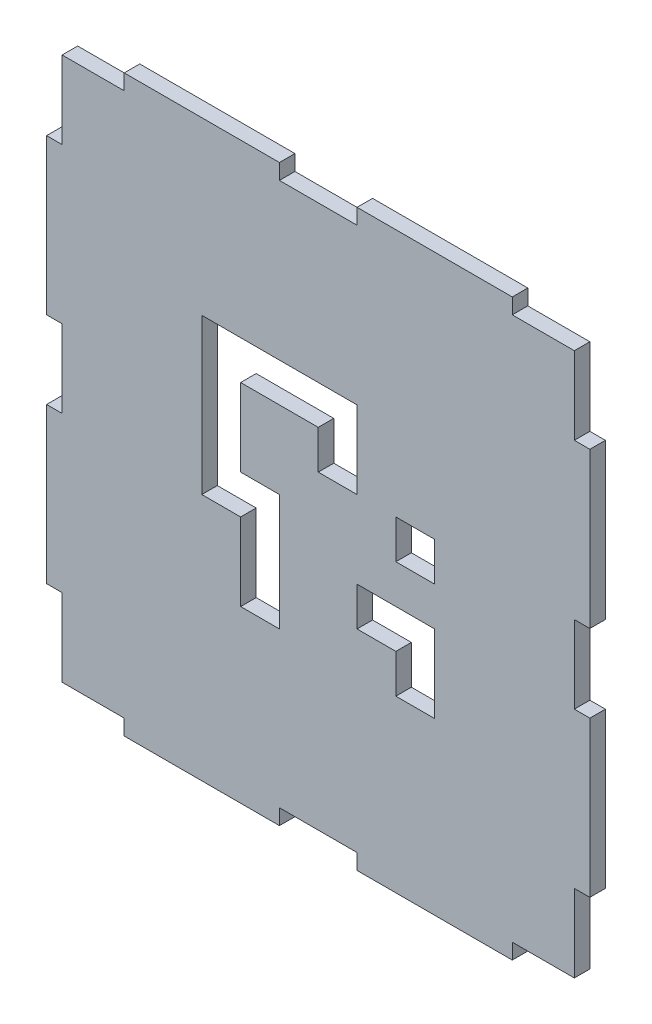
from build123d import *

# Parameters (mm, degrees)
SKETCH1_W           = 66
SKETCH1_H           = 70
BOSS_EXTRUDE1_DEPTH = 2
SKETCH2_W           = 2
SKETCH2_H           = 20
BOSS_EXTRUDE2_DEPTH = 2
SKETCH3_W           = 20
SKETCH3_H           = 2
BOSS_EXTRUDE3_DEPTH = 2
SKETCH8_W           = 5
SKETCH8_H           = 5
CUT_EXTRUDE4_DEPTH  = 10


with BuildPart() as part:
    # Sketch1 → Boss-Extrude1 (new body)
    with BuildSketch(Plane.XY):
        Rectangle(SKETCH1_W, SKETCH1_H)
    extrude(amount=BOSS_EXTRUDE1_DEPTH)

    # Sketch2 → Boss-Extrude2 (add)
    with BuildSketch(Plane(origin=(0, 0, 0), x_dir=(-1, 0, 0), z_dir=(0, 0, -1))):
        with Locations((34, -15)):
            Rectangle(SKETCH2_W, SKETCH2_H)
        with Locations((34, 15)):
            Rectangle(SKETCH2_W, SKETCH2_H)
        with Locations((-34, -15)):
            Rectangle(SKETCH2_W, SKETCH2_H)
        with Locations((-34, 15)):
            Rectangle(SKETCH2_W, SKETCH2_H)
    extrude(amount=-BOSS_EXTRUDE2_DEPTH)

    # Sketch3 → Boss-Extrude3 (add)
    with BuildSketch(Plane(origin=(0, 0, 0), x_dir=(-1, 0, 0), z_dir=(0, 0, -1))):
        with Locations((-15, 36)):
            Rectangle(SKETCH3_W, SKETCH3_H)
        with Locations((15, 36)):
            Rectangle(SKETCH3_W, SKETCH3_H)
        with Locations((-15, -36)):
            Rectangle(SKETCH3_W, SKETCH3_H)
        with Locations((15, -36)):
            Rectangle(SKETCH3_W, SKETCH3_H)
    extrude(amount=-BOSS_EXTRUDE3_DEPTH)

    # Sketch8 → Cut-Extrude4 (cut)
    with BuildSketch(Plane(origin=(0, 0, 0), x_dir=(-1, 0, 0), z_dir=(0, 0, -1))):
        with Locations((-12.5, -12.550886484)):
            Rectangle(SKETCH8_W, SKETCH8_H)
        with Locations((-12.5, -7.550886484)):
            Rectangle(SKETCH8_W, SKETCH8_H)
        with Locations((-7.5, -7.550886484)):
            Rectangle(SKETCH8_W, SKETCH8_H)
        with Locations((-12.5, 2.449113516)):
            Rectangle(SKETCH8_W, SKETCH8_H)
        with Locations((-2.5, 7.449113516)):
            Rectangle(SKETCH8_W, SKETCH8_H)
        with Locations((-2.5, 12.449113516)):
            Rectangle(SKETCH8_W, SKETCH8_H)
        with Locations((2.5, 12.449113516)):
            Rectangle(SKETCH8_W, SKETCH8_H)
        with Locations((7.5, 12.449113516)):
            Rectangle(SKETCH8_W, SKETCH8_H)
        with Locations((12.5, 12.449113516)):
            Rectangle(SKETCH8_W, SKETCH8_H)
        with Locations((12.5, 7.449113516)):
            Rectangle(SKETCH8_W, SKETCH8_H)
        with Locations((12.5, 2.449113516)):
            Rectangle(SKETCH8_W, SKETCH8_H)
        with Locations((12.5, -2.550886484)):
            Rectangle(SKETCH8_W, SKETCH8_H)
        with Locations((7.5, -2.550886484)):
            Rectangle(SKETCH8_W, SKETCH8_H)
        with Locations((7.5, -7.550886484)):
            Rectangle(SKETCH8_W, SKETCH8_H)
        with Locations((7.5, -12.550886484)):
            Rectangle(SKETCH8_W, SKETCH8_H)
    extrude(amount=-CUT_EXTRUDE4_DEPTH, mode=Mode.SUBTRACT)


solid = part.part
